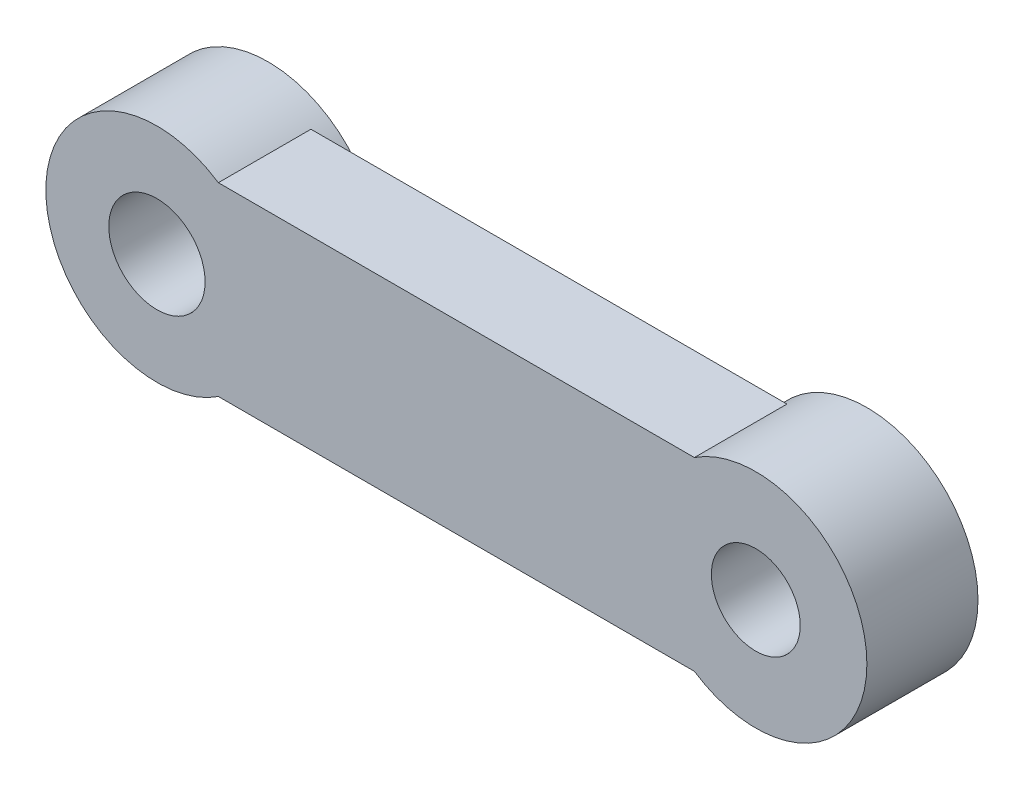
from build123d import *

# Parameters (mm, degrees)
SKETCH14_R          = 1.3
SKETCH14_R_2        = 1.2
BOSS_EXTRUDE1_DEPTH = 2.5
SKETCH15_R          = 3
SKETCH15_R_2        = 1.2
SKETCH15_R_3        = 1.3
BOSS_EXTRUDE2_DEPTH = 3


with BuildPart() as part:
    # Sketch14 → Boss-Extrude1 (new body)
    with BuildSketch(Plane.XY):
        with BuildLine():
            Line((16.17, 2.5), (0, 2.5))
            ThreePointArc((0, 2.5), (-2.5, 0), (0, -2.5))
            Line((0, -2.5), (16.17, -2.5))
            ThreePointArc((16.17, -2.5), (18.67, 0), (16.17, 2.5))
        make_face()
        Circle(SKETCH14_R, mode=Mode.SUBTRACT)
        with Locations((16.17, 0)):
            Circle(SKETCH14_R_2, mode=Mode.SUBTRACT)
    extrude(amount=BOSS_EXTRUDE1_DEPTH)

    # Sketch15 → Boss-Extrude2 (add)
    with BuildSketch(Plane.XY.offset(2.5)):
        with Locations((16.17, 0)):
            Circle(SKETCH15_R)
        with Locations((16.17, 0)):
            Circle(SKETCH15_R_2, mode=Mode.SUBTRACT)
        Circle(SKETCH15_R)
        Circle(SKETCH15_R_3, mode=Mode.SUBTRACT)
    extrude(amount=-BOSS_EXTRUDE2_DEPTH)


solid = part.part
